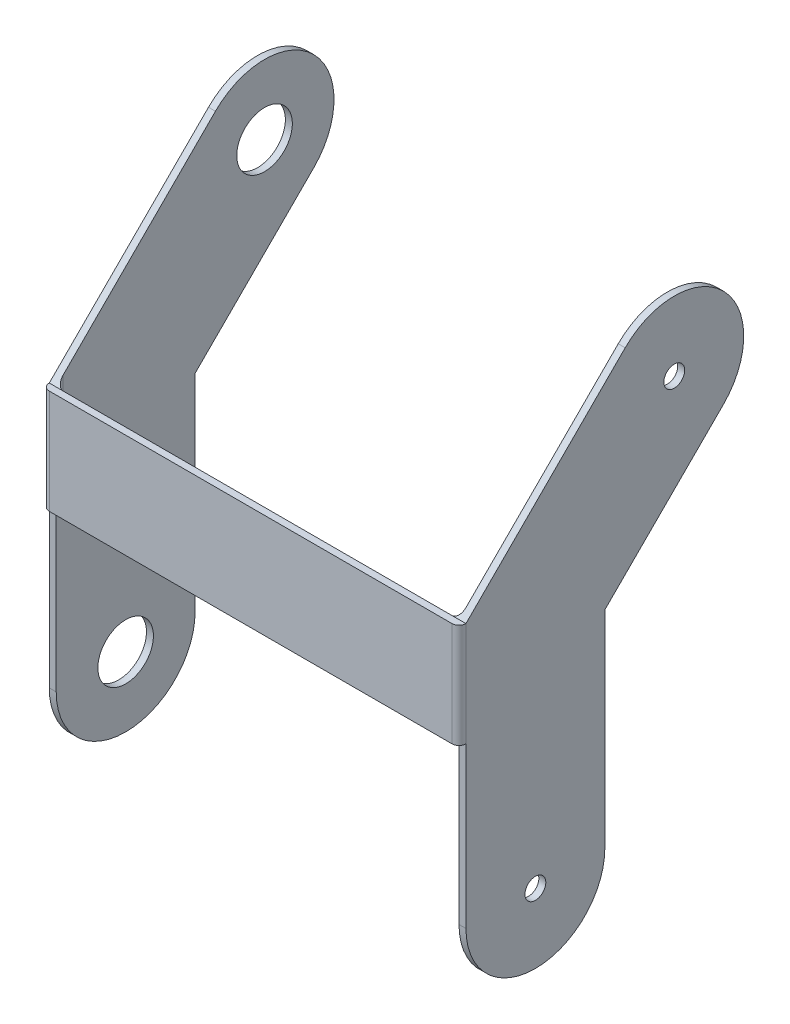
from build123d import *

# Parameters (mm, degrees)
SKETCH1_R           = 1.5
BOSS_EXTRUDE1_DEPTH = 1
BOSS_EXTRUDE2_START = -1
SKETCH2_W           = 1
SKETCH2_H           = 15
BOSS_EXTRUDE2_DEPTH = 30
FILLET1_R           = 1
CUT_EXTRUDE1_REACH  = 62
SKETCH3_R           = 4


with BuildPart() as part:
    # Sketch1 → Boss-Extrude1 (new body)
    with BuildSketch(Plane(origin=(0, 0, 0), x_dir=(0, 0, -1), z_dir=(1, 0, 0))):
        with BuildLine():
            Line((0, 0), (22.928644487, 22.928644487))
            ThreePointArc((22.928644487, 22.928644487), (37.07078011, 22.928644487), (37.07078011, 8.786508863))
            Line((37.07078011, 8.786508863), (20, -8.284271247))
            Line((20, -8.284271247), (20, -38.019))
            ThreePointArc((20, -38.019), (10, -48.019), (0, -38.019))
            Line((0, -38.019), (0, 0))
        make_face()
        with Locations((29.999712299, 15.857576675)):
            Circle(SKETCH1_R, mode=Mode.SUBTRACT)
        with Locations((10, -38.019)):
            Circle(SKETCH1_R, mode=Mode.SUBTRACT)
    boss_extrude1 = extrude(amount=BOSS_EXTRUDE1_DEPTH)

    # Sketch2 → Boss-Extrude2 (add)
    with BuildSketch(Plane(origin=(1, 0, 0), x_dir=(0, 0, -1), z_dir=(1, 0, 0)).offset(BOSS_EXTRUDE2_START)):
        with Locations((-0.5, -7.5)):
            Rectangle(SKETCH2_W, SKETCH2_H)
    boss_extrude2 = extrude(amount=BOSS_EXTRUDE2_DEPTH)

    # Mirror2: Boss-Extrude1, Boss-Extrude2 across plane
    add(boss_extrude1.mirror(Plane.ZY.offset(-30)))
    add(boss_extrude2.mirror(Plane.ZY.offset(-30)))

    # Fillet1
    fillet1_edges = [part.edges().sort_by_distance(p)[0] for p in [
        (1, -7.5, 0),
        (59, -7.5, 0),
        (0, -7.5, 1),
        (60, -7.5, 1),
    ]]
    fillet(fillet1_edges, radius=FILLET1_R)

    # Sketch3 → Cut-Extrude1 (cut, up to next)
    with BuildSketch(Plane.ZY, mode=Mode.PRIVATE) as cut_extrude1_sk1:
        with Locations((-29.999712299, 15.857576675)):
            Circle(SKETCH3_R)
    cut_extrude1_tool1 = extrude(cut_extrude1_sk1.sketch, amount=-CUT_EXTRUDE1_REACH, mode=Mode.PRIVATE) & part.part
    add(cut_extrude1_tool1.solids().sort_by_distance((0, 15.857577, -29.999712))[0], mode=Mode.SUBTRACT)
    # Sketch3 → Cut-Extrude1 (cut, up to next)
    with BuildSketch(Plane.ZY, mode=Mode.PRIVATE) as cut_extrude1_sk2:
        with Locations((-10, -38.019)):
            Circle(SKETCH3_R)
    cut_extrude1_tool2 = extrude(cut_extrude1_sk2.sketch, amount=-CUT_EXTRUDE1_REACH, mode=Mode.PRIVATE) & part.part
    add(cut_extrude1_tool2.solids().sort_by_distance((0, -38.019, -10))[0], mode=Mode.SUBTRACT)


solid = part.part
